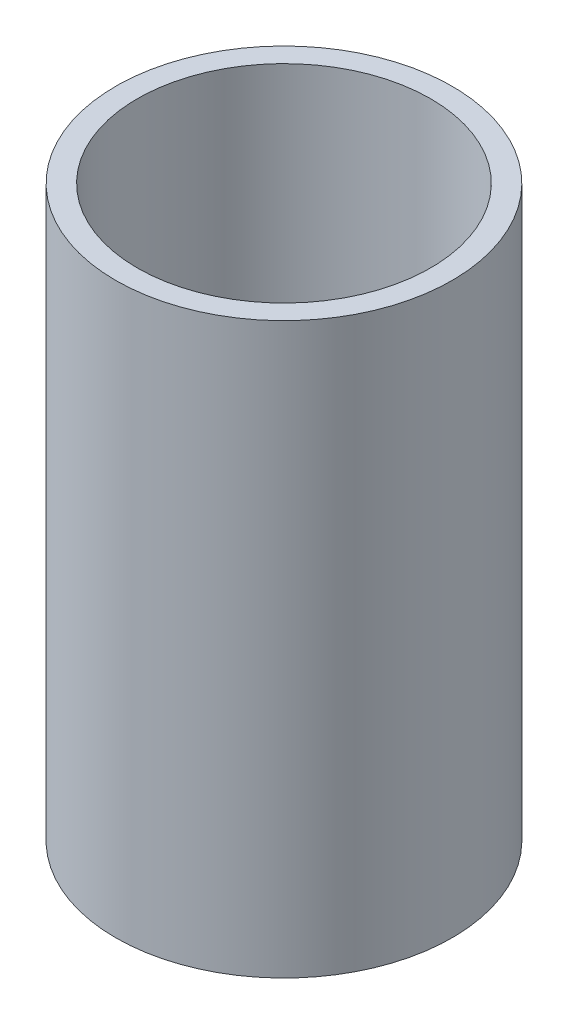
from build123d import *

# Parameters (mm, degrees)
SKETCH2_R           = 9.75
SKETCH2_R_2         = 8.5
BOSS_EXTRUDE1_DEPTH = 33
SKETCH3_R           = 8.5
SKETCH3_R_2         = 5
BOSS_EXTRUDE2_DEPTH = 2


with BuildPart() as part:
    # Sketch2 → Boss-Extrude1 (new body)
    with BuildSketch(Plane(origin=(0, 0, 0), x_dir=(1, 0, 0), z_dir=(0, 1, 0))):
        Circle(SKETCH2_R)
        Circle(SKETCH2_R_2, mode=Mode.SUBTRACT)
    extrude(amount=BOSS_EXTRUDE1_DEPTH)

    # Sketch3 → Boss-Extrude2 (add)
    with BuildSketch(Plane(origin=(0, 0, 0), x_dir=(1, 0, 0), z_dir=(0, 1, 0))):
        Circle(SKETCH3_R)
        Circle(SKETCH3_R_2, mode=Mode.SUBTRACT)
    extrude(amount=BOSS_EXTRUDE2_DEPTH)


solid = part.part
